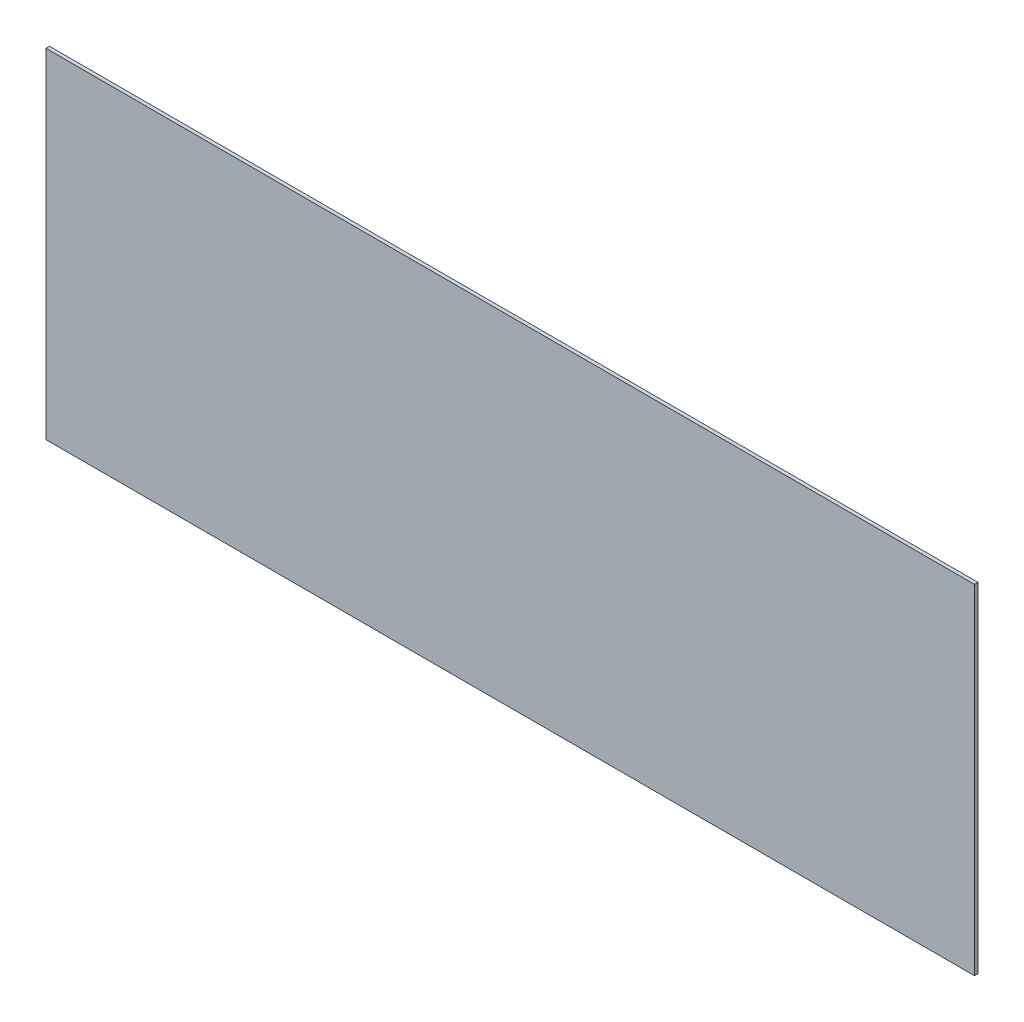
from build123d import *

# Parameters (mm, degrees)
SKETCH1_W           = 835.025
SKETCH1_H           = 304.8
BOSS_EXTRUDE1_DEPTH = 1.5875


with BuildPart() as part:
    # Sketch1 → Boss-Extrude1 (new body, symmetric)
    with BuildSketch(Plane.XY):
        Rectangle(SKETCH1_W, SKETCH1_H)
    extrude(amount=BOSS_EXTRUDE1_DEPTH, both=True)


solid = part.part
